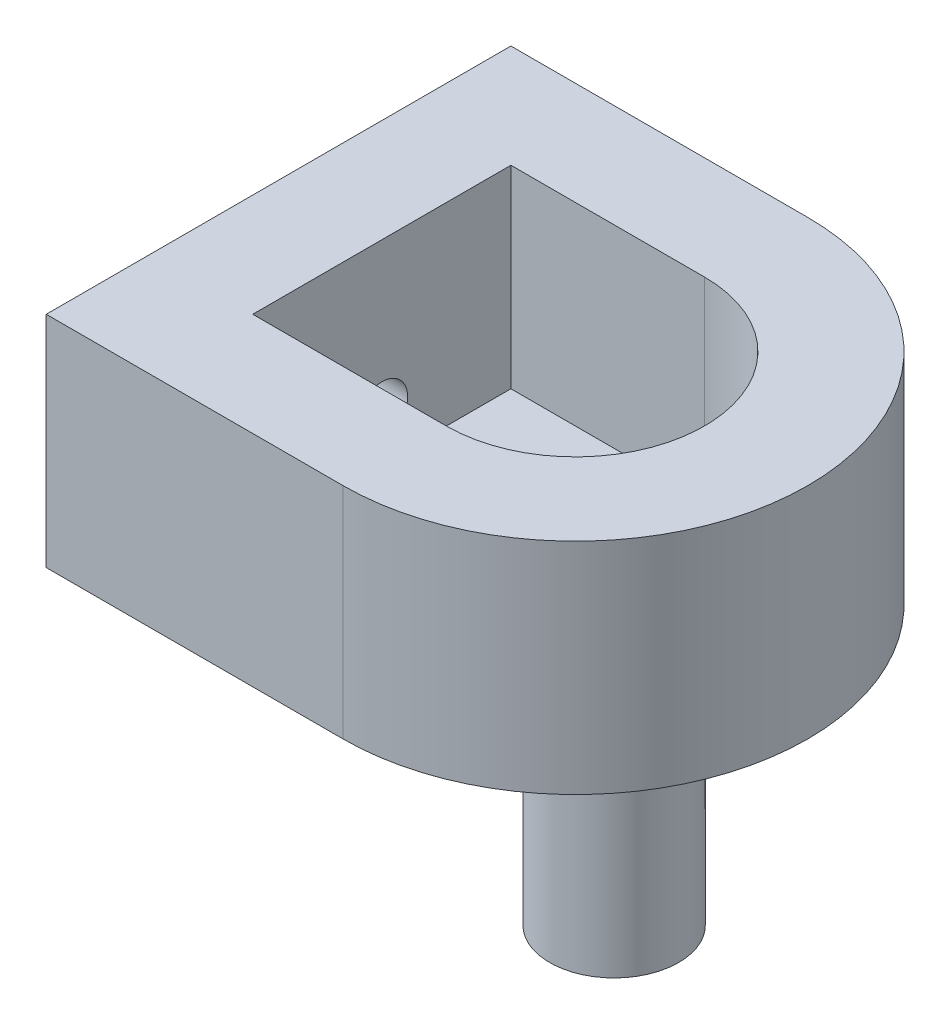
from build123d import *

# Parameters (mm, degrees)
BOSS_EXTRUDE1_DEPTH     = 15
BOSS_EXTRUDE2_DEPTH     = 2
SKETCH2_R               = 5
SKETCH2_R_2             = 3
BOSS_EXTRUDE3_DEPTH     = 20
SKETCH2_3_R             = 3
CUT_EXTRUDE1_DEPTH      = 18
CUT_EXTRUDE1_DEPTH_BACK = 36.397740041
SKETCH3_R               = 2
CUT_EXTRUDE2_DEPTH      = 20


with BuildPart() as part:
    # Sketch1 → Boss-Extrude1 (new body)
    with BuildSketch(Plane(origin=(0, 0, 0), x_dir=(1, 0, 0), z_dir=(0, 1, 0))):
        with BuildLine():
            Line((-23, 18), (0, 18))
            ThreePointArc((0, 18), (18, 0), (0, -18))
            Line((0, -18), (-23, -18))
            Line((-23, -18), (-23, 18))
        make_face()
        with BuildLine():
            Line((-15, 10), (0, 10))
            ThreePointArc((0, 10), (10, 0), (0, -10))
            Line((0, -10), (-15, -10))
            Line((-15, -10), (-15, 10))
        make_face(mode=Mode.SUBTRACT)
    extrude(amount=BOSS_EXTRUDE1_DEPTH)

    # Sketch1_2 → Boss-Extrude2 (add)
    with BuildSketch(Plane(origin=(0, 0, 0), x_dir=(1, 0, 0), z_dir=(0, 1, 0))):
        with BuildLine():
            Line((-23, 18), (0, 18))
            ThreePointArc((0, 18), (18, 0), (0, -18))
            Line((0, -18), (-23, -18))
            Line((-23, -18), (-23, 18))
        make_face()
    extrude(amount=-BOSS_EXTRUDE2_DEPTH)

    # Sketch2 → Boss-Extrude3 (add)
    with BuildSketch(Plane(origin=(0, -2, 0), x_dir=(-1, 0, 0), z_dir=(0, -1, 0))):
        with Locations(Location((-3, 0, 0), (0, 0, 90))):
            Circle(SKETCH2_R)
        with Locations((-3, 0)):
            Circle(SKETCH2_R_2, mode=Mode.SUBTRACT)
        with Locations((-3, 0)):
            Circle(SKETCH2_R_2)
    extrude(amount=BOSS_EXTRUDE3_DEPTH)

    # Sketch2_3 → Cut-Extrude1 (cut, two sides)
    with BuildSketch(Plane(origin=(0, -2, 0), x_dir=(-1, 0, 0), z_dir=(0, -1, 0))) as cut_extrude1_sk:
        with Locations(Location((-3, 0, 0), (0, 0, 90))):
            Circle(SKETCH2_3_R)
    extrude(amount=CUT_EXTRUDE1_DEPTH, mode=Mode.SUBTRACT)
    extrude(cut_extrude1_sk.sketch, amount=-CUT_EXTRUDE1_DEPTH_BACK, mode=Mode.SUBTRACT)

    # Sketch3 → Cut-Extrude2 (cut)
    with BuildSketch(Plane.ZY.offset(23)):
        with Locations((0, 3.47)):
            Circle(SKETCH3_R)
    extrude(amount=-CUT_EXTRUDE2_DEPTH, mode=Mode.SUBTRACT)


with BuildPart() as body_2:
    # Split1: the piece on the far side of the plane
    add(part.part)
    split(bisect_by=Plane(origin=(0, -2, 0), x_dir=(0, 0, -1), z_dir=(0, -1, 0)), keep=Keep.BOTTOM)


with BuildPart() as part_1:
    add(part.part)

    # Split1
    split(bisect_by=Plane(origin=(0, -2, 0), x_dir=(0, 0, -1), z_dir=(0, -1, 0)), keep=Keep.TOP)


solid = Compound([body_2.part, part_1.part])
